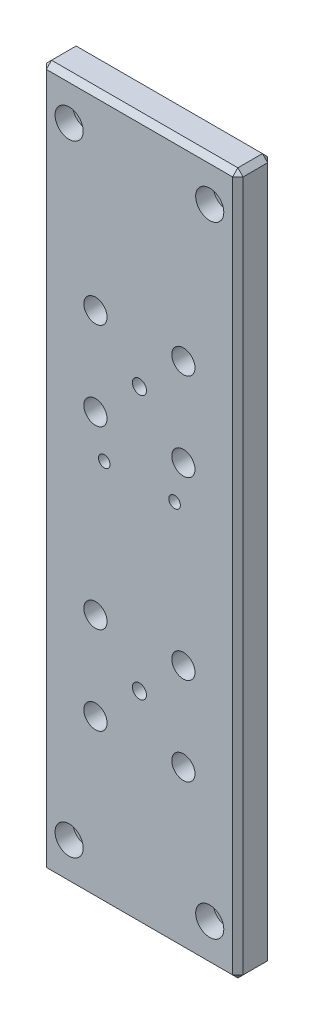
from build123d import *

# Parameters (mm, degrees)
SKETCH1_W            = 56
SKETCH1_H            = 199.6
EXTRUDE1_DEPTH       = 10
CHAMFER1_SIZE        = 1.5
HOLEWZD1_D           = 4
HOLEWZD1_DEPTH       = 5
HOLEWZD4_D           = 6.6
HOLEWZD4_DEPTH       = 10
HOLEWZD5_D           = 4
HOLEWZD5_DEPTH       = 10
HOLEWZD6_D           = 4
HOLEWZD6_DEPTH       = 5
HOLEWZD7_D           = 3.3
HOLEWZD9_D           = 4.5
HOLEWZD9_CBORE_D     = 8
HOLEWZD9_CBORE_DEPTH = 5


with BuildPart() as part:
    # Sketch1 → Extrude1 (new body)
    with BuildSketch(Plane.XY):
        with Locations((0, 78.3)):
            Rectangle(SKETCH1_W, SKETCH1_H)
    extrude(amount=EXTRUDE1_DEPTH)

    # Chamfer1
    chamfer1_edges = [part.edges().sort_by_distance(p)[0] for p in [
        (28, 78.3, 10),
        (0, 178.1, 10),
        (-28, 78.3, 10),
        (0, 178.1, 0),
        (28, 78.3, 0),
        (0, -21.5, 0),
        (-28, 78.3, 0),
        (0, -21.5, 10),
        (-28, 178.1, 5),
        (28, 178.1, 5),
        (28, -21.5, 5),
        (-28, -21.5, 5),
    ]]
    chamfer(chamfer1_edges, length=CHAMFER1_SIZE)

    # HoleWzd1
    with Locations(Plane(origin=(-28, 98.3, 0), x_dir=(-1, 0, 0), z_dir=(0, 0, -1))):
        with Locations((-40, -108.3), (-16, -108.3), (-40, 68.3), (-16, 68.3)):
            Hole(HOLEWZD1_D / 2, depth=HOLEWZD1_DEPTH)

    # HoleWzd4
    with Locations(Plane(origin=(0, 0, 0), x_dir=(-1, 0, 0), z_dir=(0, 0, -1))):
        with Locations((-12.5, 99.196924858), (12.5, 124.196924858), (-12.5, 124.196924858), (12.5, 99.196924858), (-12.5, 49.196924858), (12.5, 49.196924858), (12.5, 24.196924858), (-12.5, 24.196924858)):
            Hole(HOLEWZD4_D / 2, depth=HOLEWZD4_DEPTH)

    # HoleWzd5
    with Locations(Plane(origin=(0, 0, 0), x_dir=(-1, 0, 0), z_dir=(0, 0, -1))):
        with Locations((0, 111.696924858), (0, 36.696924858)):
            Hole(HOLEWZD5_D / 2, depth=HOLEWZD5_DEPTH)

    # HoleWzd6
    with Locations(Plane(origin=(0, 0, 0), x_dir=(-1, 0, 0), z_dir=(0, 0, -1))):
        with Locations((17.5, 88.301), (-17.5, 88.301)):
            Hole(HOLEWZD6_D / 2, depth=HOLEWZD6_DEPTH)

    # HoleWzd7 (through all)
    with Locations(Plane(origin=(0, 0, 0), x_dir=(-1, 0, 0), z_dir=(0, 0, -1))):
        with Locations((10, 88.301), (-10, 88.301)):
            Hole(HOLEWZD7_D / 2)

    # HoleWzd9 (through all)
    with Locations(Plane.XY.offset(10)):
        with Locations((20, -10), (-20, -10), (20, 166.6), (-20, 166.6)):
            CounterBoreHole(HOLEWZD9_D / 2, HOLEWZD9_CBORE_D / 2, HOLEWZD9_CBORE_DEPTH)


solid = part.part
